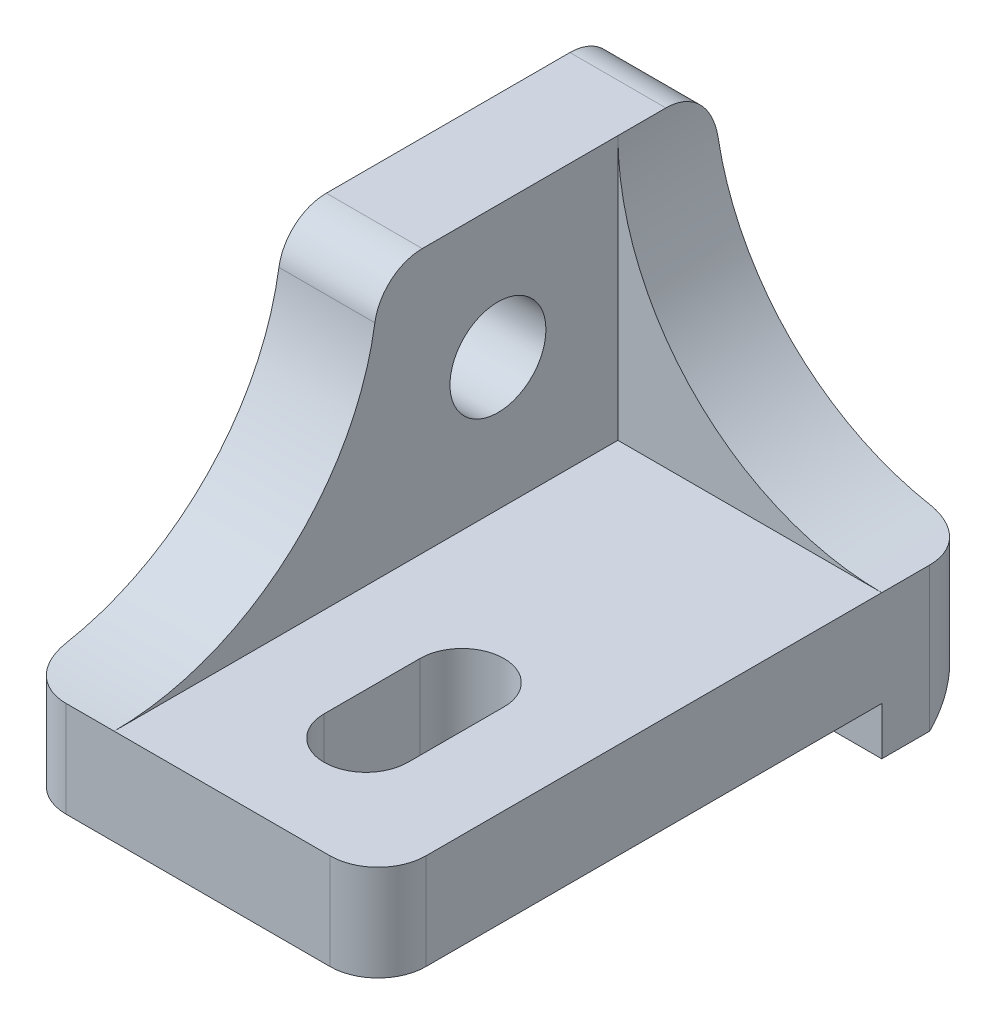
from build123d import *

# Parameters (mm, degrees)
RESSALTO_EXTRUS_O1_DEPTH = 25
RESSALTO_EXTRUS_O2_DEPTH = 4
RESSALTO_EXTRUS_O4_DEPTH = 4
PADR_O_LINEAR1_COUNT     = 2
PADR_O_LINEAR1_PITCH     = 11
CORTE_EXTRUS_O1_DEPTH    = 7
ESBO_O6_R                = 2
CORTE_EXTRUS_O2_DEPTH    = 5
CORTE_EXTRUS_O3_DEPTH    = 5
FILETE2_R                = 2
FILETE3_R                = 2
FILETE4_R                = 2
FILETE5_R                = 2
FILETE6_R                = 2


with BuildPart() as part:
    # Esboço1 → Ressalto-extrusão1 (new body)
    with BuildSketch(Plane.XY):
        Polygon((0, 0), (-15, 0), (-15, 15), (-11, 15), (-11, 4), (0, 4), align=None)
    extrude(amount=RESSALTO_EXTRUS_O1_DEPTH)

    # Esboço2 → Ressalto-extrusão2 (add)
    with BuildSketch(Plane(origin=(0, 0, 0), x_dir=(-1, 0, 0), z_dir=(0, 0, -1))):
        with BuildLine():
            Line((0, 4), (11, 4))
            Line((11, 4), (11, 15))
            ThreePointArc((11, 15), (7.778174593, 7.221825407), (0, 4))
        make_face()
    extrude(amount=-RESSALTO_EXTRUS_O2_DEPTH)

    # Esboço3 → Ressalto-extrusão4 (add)
    with BuildSketch(Plane(origin=(0, 0, 0), x_dir=(0, 0, -1), z_dir=(1, 0, 0))):
        Polygon((0, 0), (-4, 0), (-4, -2), (-2, -2), align=None)
    ressalto_extrus_o4 = extrude(amount=-RESSALTO_EXTRUS_O4_DEPTH)

    # Padrão linear1: Ressalto-extrusão4 ×2
    with Locations(*[(-i * PADR_O_LINEAR1_PITCH, 0, 0) for i in range(1, PADR_O_LINEAR1_COUNT)]):
        add(ressalto_extrus_o4)

    # Esboço5 → Corte-extrusão1 (cut, through all)
    with BuildSketch(Plane(origin=(0, 4, 0), x_dir=(1, 0, 0), z_dir=(0, 1, 0))):
        with BuildLine():
            Line((-7.25, -20), (-7.25, -16))
            ThreePointArc((-7.25, -16), (-5.5, -14.25), (-3.75, -16))
            Line((-3.75, -16), (-3.75, -20))
            ThreePointArc((-3.75, -20), (-5.5, -21.75), (-7.25, -20))
        make_face()
    extrude(amount=-CORTE_EXTRUS_O1_DEPTH, mode=Mode.SUBTRACT)

    # Esboço6 → Corte-extrusão2 (cut, through all)
    with BuildSketch(Plane(origin=(-11, 0, 0), x_dir=(0, 0, -1), z_dir=(1, 0, 0))):
        with Locations((-9, 9.5)):
            Circle(ESBO_O6_R)
    extrude(amount=-CORTE_EXTRUS_O2_DEPTH, mode=Mode.SUBTRACT)

    # Esboço8 → Corte-extrusão3 (cut, through all)
    with BuildSketch(Plane(origin=(-11, 0, 0), x_dir=(0, 0, -1), z_dir=(1, 0, 0))):
        with BuildLine():
            Line((-25, 4), (-25, 15))
            Line((-25, 15), (-14, 15))
            ThreePointArc((-14, 15), (-17.221825407, 7.221825407), (-25, 4))
        make_face()
    extrude(amount=-CORTE_EXTRUS_O3_DEPTH, mode=Mode.SUBTRACT)

    # Filete2
    filete2_edges = [part.edges().sort_by_distance(p)[0] for p in [
        (-13, 15, 14),
    ]]
    fillet(filete2_edges, radius=FILETE2_R)

    # Filete3
    filete3_edges = [part.edges().sort_by_distance(p)[0] for p in [
        (0, 2, 25),
    ]]
    fillet(filete3_edges, radius=FILETE3_R)

    # Filete4
    filete4_edges = [part.edges().sort_by_distance(p)[0] for p in [
        (-15, 2, 25),
    ]]
    fillet(filete4_edges, radius=FILETE4_R)

    # Filete5
    filete5_edges = [part.edges().sort_by_distance(p)[0] for p in [
        (0, 2, 0),
    ]]
    fillet(filete5_edges, radius=FILETE5_R)

    # Filete6
    filete6_edges = [part.edges().sort_by_distance(p)[0] for p in [
        (-13, 15, 0),
    ]]
    fillet(filete6_edges, radius=FILETE6_R)


solid = part.part
